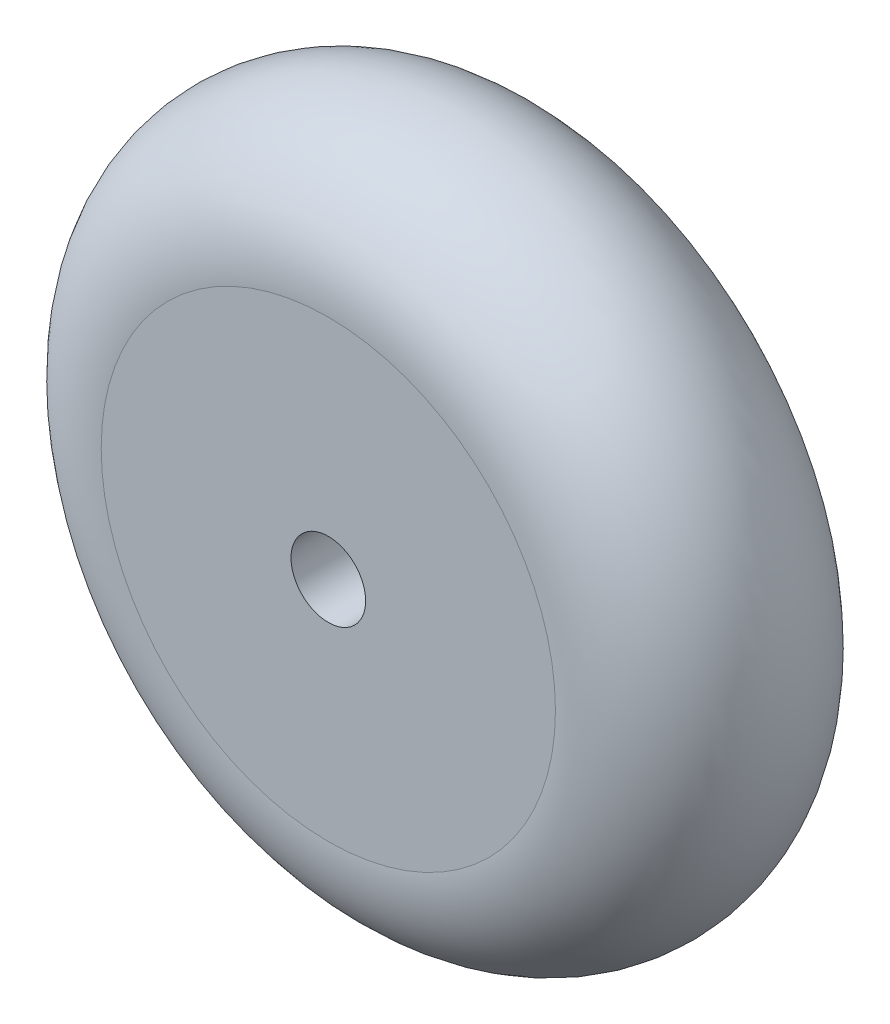
from build123d import *

# Parameters (mm, degrees)
SKETCH2_R          = 4
CUT_EXTRUDE1_DEPTH = 26.017170827


with BuildPart() as part:
    # Sketch1 → Revolve1 (revolve)
    with BuildSketch(Plane(origin=(0, 0, 0), x_dir=(1, 0, 0), z_dir=(0, 1, 0))):
        with BuildLine():
            Line((0, 0), (0, 25))
            Line((0, 25), (-24.344589438, 25))
            ThreePointArc((-24.344589438, 25), (-37.517170727, 12.5), (-24.344589438, 0))
            Line((-24.344589438, 0), (0, 0))
        make_face()
    revolve(axis=Axis((0, 0, 0), (0, 0, -1)))

    # Sketch2 → Cut-Extrude1 (cut, through all)
    with BuildSketch(Plane(origin=(0, 0, -25), x_dir=(-1, 0, 0), z_dir=(0, 0, -1))):
        Circle(SKETCH2_R)
    extrude(amount=-CUT_EXTRUDE1_DEPTH, mode=Mode.SUBTRACT)


solid = part.part
